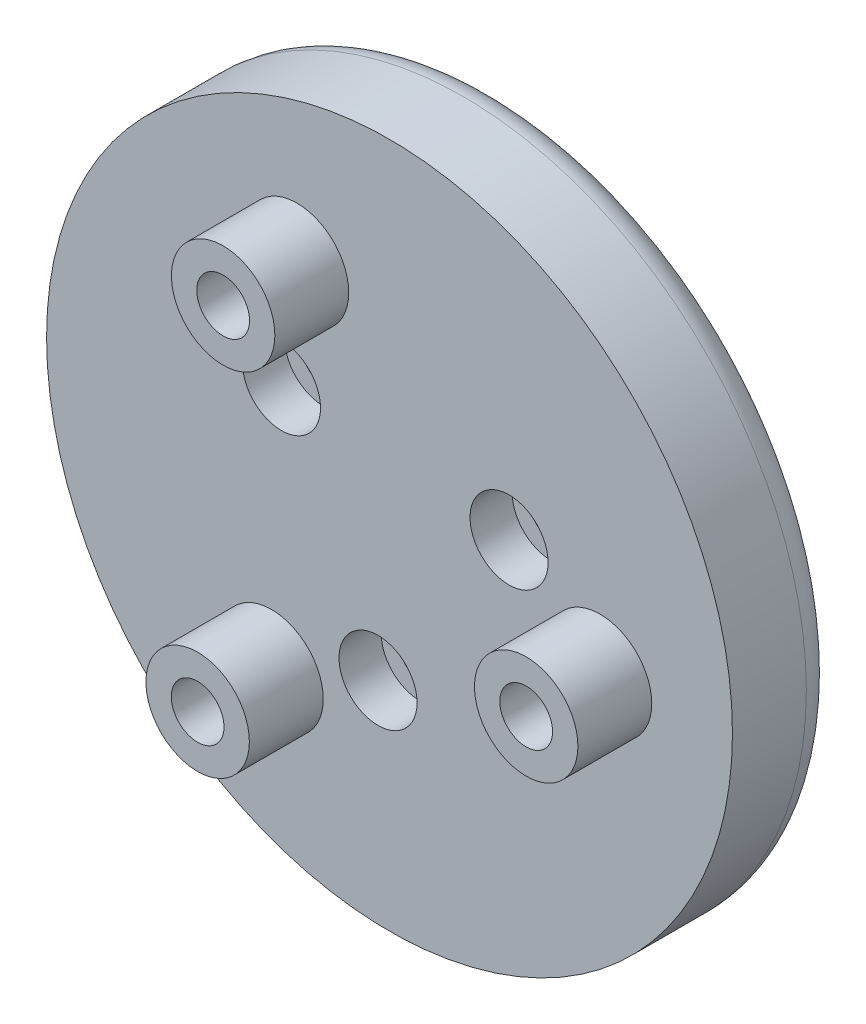
from build123d import *

# Parameters (mm, degrees)
SKETCH1_R               = 16.25
SKETCH1_R_2             = 1
SKETCH1_R_3             = 1.25
BOSS_EXTRUDE1_DEPTH     = 5
FILLET1_R               = 1.5
SKETCH2_R               = 2.45
BOSS_EXTRUDE2_DEPTH     = 3.5
SKETCH4_R               = 1.25
CUT_EXTRUDE1_DEPTH      = 1
CUT_EXTRUDE1_DEPTH_BACK = 9.5
SKETCH5_R               = 1.85
CUT_EXTRUDE2_DEPTH      = 2


with BuildPart() as part:
    # Sketch1 → Boss-Extrude1 (new body)
    with BuildSketch(Plane.XY):
        Circle(SKETCH1_R)
        with Locations((-0.544723392, -6.226216863)):
            Circle(SKETCH1_R_2, mode=Mode.SUBTRACT)
        with Locations((-5.119700277, 3.584852727)):
            Circle(SKETCH1_R_2, mode=Mode.SUBTRACT)
        with Locations((5.664423669, 2.641364136)):
            Circle(SKETCH1_R_2, mode=Mode.SUBTRACT)
        with Locations((-5.591929035, -8.290375726)):
            Circle(SKETCH1_R_3, mode=Mode.SUBTRACT)
        with Locations((-4.383711468, 8.987940463)):
            Circle(SKETCH1_R_3, mode=Mode.SUBTRACT)
        with Locations((9.975640503, -0.697564737)):
            Circle(SKETCH1_R_3, mode=Mode.SUBTRACT)
    extrude(amount=BOSS_EXTRUDE1_DEPTH)

    # Fillet1
    fillet1_edges = [part.edges().sort_by_distance(p)[0] for p in [
        (-16.25, 0, 0),
    ]]
    fillet(fillet1_edges, radius=FILLET1_R)

    # Sketch2 → Boss-Extrude2 (add)
    with BuildSketch(Plane.XY.offset(5)):
        with Locations((-5.591929035, -8.290375726)):
            Circle(SKETCH2_R)
        with Locations((-4.383711468, 8.987940463)):
            Circle(SKETCH2_R)
        with Locations((9.975640503, -0.697564737)):
            Circle(SKETCH2_R)
    extrude(amount=BOSS_EXTRUDE2_DEPTH)

    # Sketch4 → Cut-Extrude1 (cut, two sides)
    with BuildSketch(Plane(origin=(0, 0, 0), x_dir=(-1, 0, 0), z_dir=(0, 0, -1))) as cut_extrude1_sk:
        with Locations((4.383711468, 8.987940463)):
            Circle(SKETCH4_R)
        with Locations((-9.975640503, -0.697564737)):
            Circle(SKETCH4_R)
        with Locations((5.591929035, -8.290375726)):
            Circle(SKETCH4_R)
    extrude(amount=CUT_EXTRUDE1_DEPTH, mode=Mode.SUBTRACT)
    extrude(cut_extrude1_sk.sketch, amount=-CUT_EXTRUDE1_DEPTH_BACK, mode=Mode.SUBTRACT)

    # Sketch5 → Cut-Extrude2 (cut)
    with BuildSketch(Plane.XY.offset(5)):
        with Locations((5.664423669, 2.641364136)):
            Circle(SKETCH5_R)
        with Locations((-5.119700277, 3.584852727)):
            Circle(SKETCH5_R)
        with Locations((-0.544723392, -6.226216863)):
            Circle(SKETCH5_R)
    extrude(amount=-CUT_EXTRUDE2_DEPTH, mode=Mode.SUBTRACT)


solid = part.part
